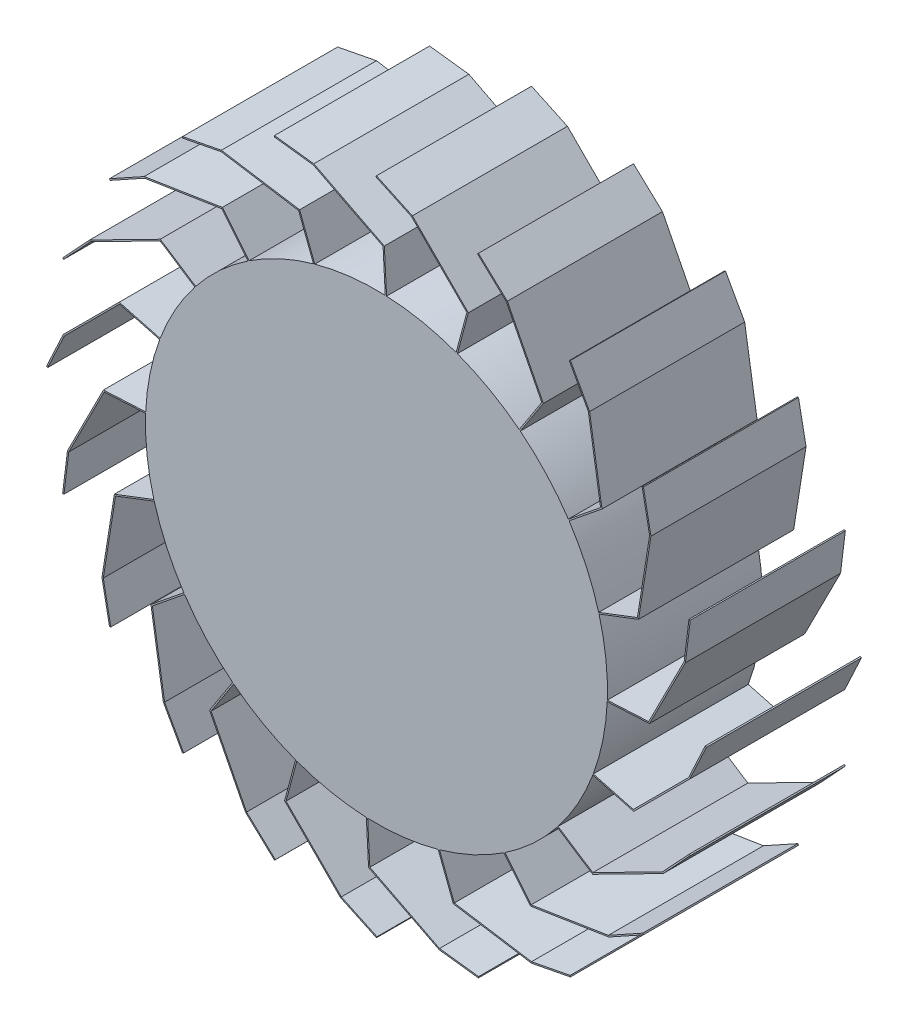
from build123d import *

# Parameters (mm, degrees)
RADDURCHMESSER_R                = 350
AUFSATZ_LINEAR_AUSTRAGEN1_DEPTH = 117.5
AUFSATZ_LINEAR_AUSTRAGEN2_DEPTH = 117.5
KREISMUSTER1_COUNT              = 20


with BuildPart() as part:
    # Raddurchmesser → Aufsatz-Linear austragen1 (new body, symmetric)
    with BuildSketch(Plane.XY):
        Circle(RADDURCHMESSER_R)
    extrude(amount=AUFSATZ_LINEAR_AUSTRAGEN1_DEPTH, both=True)

    # Schaufelschnitt → Aufsatz-Linear austragen2 (add, symmetric)
    with BuildSketch(Plane.XY):
        Polygon((122.625257529, 327.815567379), (120.693405876, 328.333205469), (137.000570821, 389.192373572), (53.213617667, 472.979326726), (-0.845236523, 498.187384426), (0, 500), (54.378467222, 474.642904296), (139.231280965, 389.790090553), align=None)
    aufsatz_linear_austragen2 = extrude(amount=AUFSATZ_LINEAR_AUSTRAGEN2_DEPTH, both=True)

    # Kreismuster1: Aufsatz-Linear austragen2 ×20 about axis
    kreismuster1_axis = Axis((0, 0, 0), (0, 0, 1))
    for i in range(1, KREISMUSTER1_COUNT):
        add(aufsatz_linear_austragen2.rotate(kreismuster1_axis, i * 360 / KREISMUSTER1_COUNT))


solid = part.part
